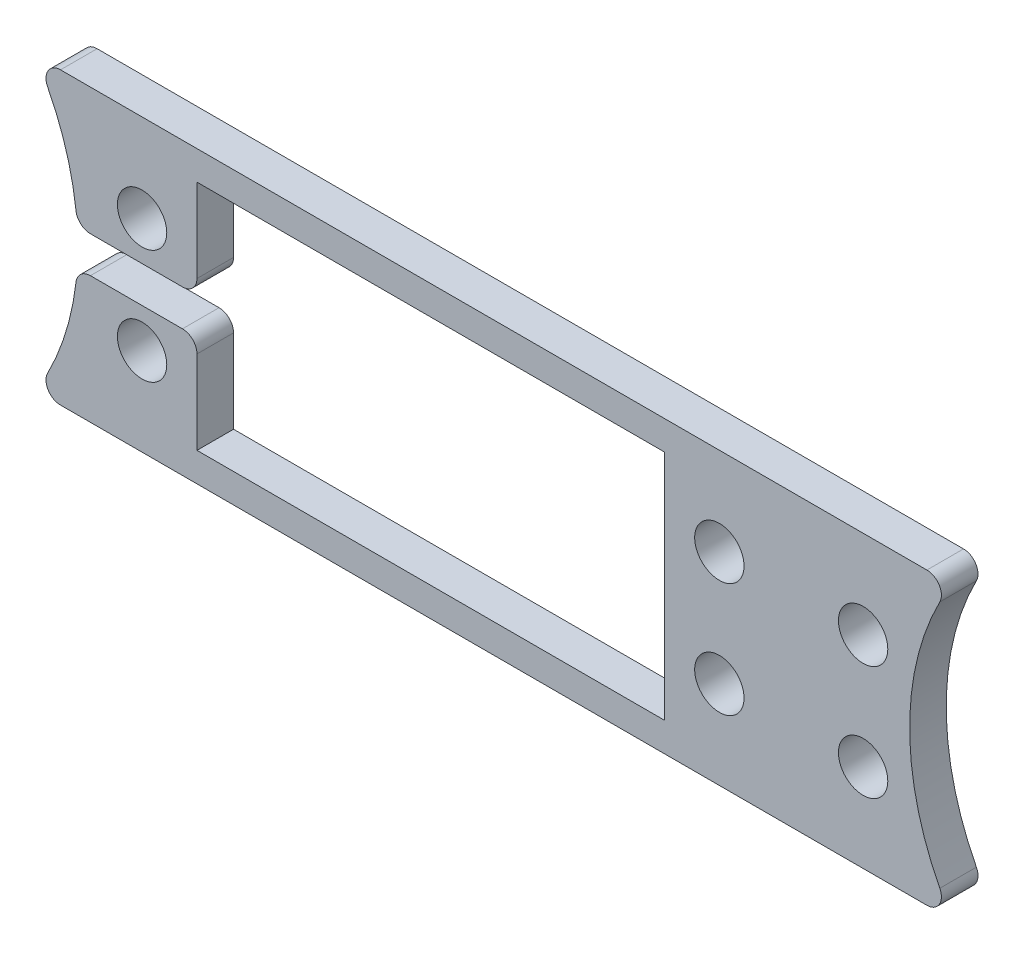
from build123d import *

# Parameters (mm, degrees)
SKETCH1_W           = 40.894
SKETCH1_H           = 20.32
BOSS_EXTRUDE1_DEPTH = 3.2004
SKETCH2_R           = 2.159
CUT_EXTRUDE1_DEPTH  = 3.2004
SKETCH3_W           = 10.481403753
SKETCH3_H           = 3.175
CUT_EXTRUDE2_DEPTH  = 3.2004
FILLET1_R           = 1.27


with BuildPart() as part:
    # Sketch1 → Boss-Extrude1 (new body)
    with BuildSketch(Plane.XY):
        with BuildLine():
            Line((0, 25.4), (80.179895682, 25.4))
            ThreePointArc((80.179895682, 25.4), (76.475447841, 12.7), (80.179895682, 0))
            Line((80.179895682, 0), (0, 0))
            ThreePointArc((0, 0), (3.704447841, 12.7), (0, 25.4))
        make_face()
        with Locations((34.579447813, 12.7)):
            Rectangle(SKETCH1_W, SKETCH1_H, mode=Mode.SUBTRACT)
    extrude(amount=BOSS_EXTRUDE1_DEPTH)

    # Sketch2 → Cut-Extrude1 (cut)
    with BuildSketch(Plane.XY.offset(3.2004)):
        with Locations((9.329447813, 17.7)):
            Circle(SKETCH2_R)
        with Locations((59.829447813, 7.7)):
            Circle(SKETCH2_R)
        with Locations((59.829447813, 17.7)):
            Circle(SKETCH2_R)
        with Locations((9.329447813, 7.7)):
            Circle(SKETCH2_R)
        with Locations((72.404688187, 17.7)):
            Circle(SKETCH2_R)
        with Locations((72.404688187, 7.7)):
            Circle(SKETCH2_R)
    extrude(amount=-CUT_EXTRUDE1_DEPTH, mode=Mode.SUBTRACT)

    # Sketch3 → Cut-Extrude2 (cut)
    with BuildSketch(Plane.XY.offset(3.2004)):
        with Locations((8.891745937, 12.7)):
            Rectangle(SKETCH3_W, SKETCH3_H)
    extrude(amount=-CUT_EXTRUDE2_DEPTH, mode=Mode.SUBTRACT)

    # Fillet1
    fillet1_edges = [part.edges().sort_by_distance(p)[0] for p in [
        (14.132447813, 11.1125, 1.6002),
        (14.132447813, 14.2875, 1.6002),
        (3.65104406, 14.2875, 1.6002),
        (3.65104406, 11.1125, 1.6002),
        (0, 25.4, 1.6002),
        (80.179895682, 25.4, 1.6002),
        (80.179895682, 0, 1.6002),
        (0, 0, 1.6002),
    ]]
    fillet(fillet1_edges, radius=FILLET1_R)


solid = part.part
